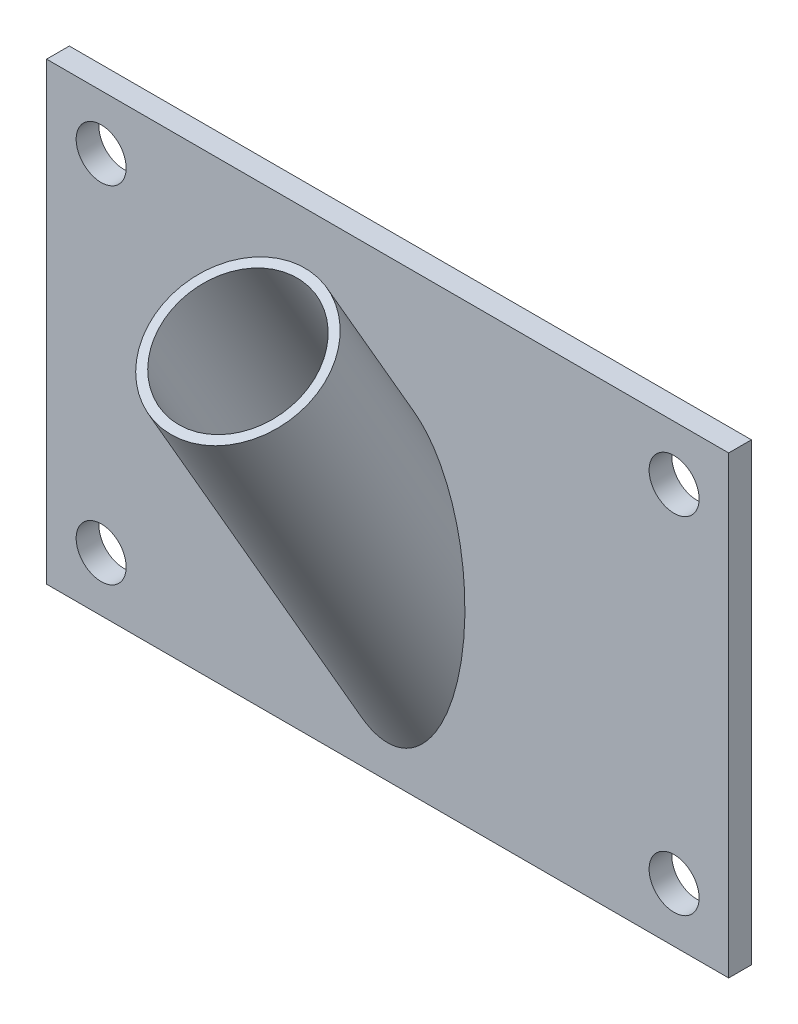
from build123d import *

# Parameters (mm, degrees)
SZKIC1_W                                = 150
SZKIC1_H                                = 100
DODANIE_WYCI_GNI_CIE1_DEPTH             = 5
OTW_R_POD_RUB_M101_D                    = 11
LUSTRO1_AT_THE_SECOND_PLANE_COPY_1_D    = 11
SZKIC4_R                                = 17
SZKIC4_R_2                              = 15
DODANIE_WYCI_GNI_CIE2_DEPTH             = 15
DODANIE_WYCI_GNI_CIE2_DIRECTION_2_REACH = 91.103


with BuildPart() as part:
    # Szkic1 → Dodanie-wyciągnięcie1 (new body)
    with BuildSketch(Plane.XY):
        Rectangle(SZKIC1_W, SZKIC1_H)
    extrude(amount=DODANIE_WYCI_GNI_CIE1_DEPTH)

    # Otwór pod śrubę M101 (through all)
    with Locations(Plane.XY.offset(5)):
        with Locations((-63, 38)):
            otw_r_pod_rub_m101 = Hole(OTW_R_POD_RUB_M101_D / 2)

    # Lustro1: Otwór pod śrubę M101 across plane
    add(otw_r_pod_rub_m101.mirror(Plane.ZX), mode=Mode.SUBTRACT)

    # Lustro1 at the second plane: Otwór pod śrubę M101 across plane
    add(otw_r_pod_rub_m101.mirror(Plane(origin=(0, 0, 0), x_dir=(0, 0, 1), z_dir=(1, 0, 0))), mode=Mode.SUBTRACT)

    # Lustro1 at the second plane copy 1 (through all)
    with Locations(Plane(origin=(0, 0, 5), x_dir=(-1, 0, 0), z_dir=(0, 0, 1))):
        with Locations((-63, 38)):
            Hole(LUSTRO1_AT_THE_SECOND_PLANE_COPY_1_D / 2)

    # Szkic4 → Dodanie-wyciągnięcie2 (add)
    with BuildSketch(Plane(origin=(0, 39.665063509, 22.900635095), x_dir=(-1, 0, 0), z_dir=(0, 0.866025404, 0.5))):
        with Locations(Location((0, 8.683075721, 0), (0, 0, 90))):  # turned: the seam where the file's is
            Circle(SZKIC4_R)
        with Locations(Location((0, 8.683075721, 0), (0, 0, 90))):  # turned: the seam where the file's is
            Circle(SZKIC4_R_2, mode=Mode.SUBTRACT)
    extrude(amount=DODANIE_WYCI_GNI_CIE2_DEPTH)

    # Dodanie-wyciągnięcie2 direction 2: up to this face of the body (flat: up to its plane)
    dodanie_wyci_gni_cie2_direction_2_end = Plane(part.part.faces().sort_by_distance((0, 0, 5))[0])
    # Szkic4 → Dodanie-wyciągnięcie2 direction 2 (add, up to the picked face)
    with BuildSketch(Plane(origin=(0, 39.665063509, 22.900635095), x_dir=(-1, 0, 0), z_dir=(0, 0.866025404, 0.5)), mode=Mode.PRIVATE) as dodanie_wyci_gni_cie2_direction_2_sk1:
        with Locations(Location((0, 8.683075721, 0), (0, 0, 90))):  # turned: the seam where the file's is
            Circle(SZKIC4_R)
        with Locations(Location((0, 8.683075721, 0), (0, 0, 90))):  # turned: the seam where the file's is
            Circle(SZKIC4_R_2, mode=Mode.SUBTRACT)
    dodanie_wyci_gni_cie2_direction_2_tool1 = split(extrude(dodanie_wyci_gni_cie2_direction_2_sk1.sketch, amount=-DODANIE_WYCI_GNI_CIE2_DIRECTION_2_REACH, mode=Mode.PRIVATE), bisect_by=dodanie_wyci_gni_cie2_direction_2_end, keep=Keep.BOTH, mode=Mode.PRIVATE)
    add(dodanie_wyci_gni_cie2_direction_2_tool1.solids().sort_by(Axis((0, 43.583109, 16.114381), (0, -0.866025404, -0.5)))[0])


solid = part.part
